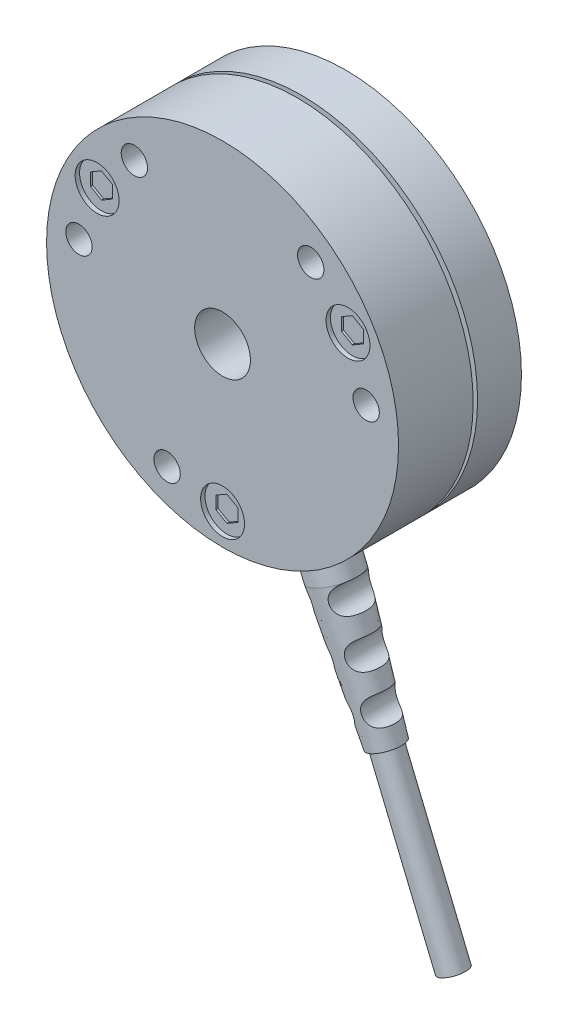
from build123d import *

# Parameters (mm, degrees)
SKETCH1_R           = 20.05
BOSS_EXTRUDE1_DEPTH = 5
SKETCH2_R           = 18.5
BOSS_EXTRUDE2_DEPTH = 0.5
SKETCH3_R           = 20.05
BOSS_EXTRUDE3_DEPTH = 8.5
SKETCH4_R           = 2.65
BOSS_EXTRUDE4_DEPTH = 37.35
CHAMFER1_SIZE       = 15
CHAMFER1_SIZE2      = 0.786116689
SKETCH5_R           = 1.5
BOSS_EXTRUDE5_DEPTH = 20
SKETCH6_R           = 1.5
CUT_EXTRUDE1_DEPTH  = 15.0000001
SKETCH9_R           = 2.5
CUT_EXTRUDE2_DEPTH  = 0.5
CUT_EXTRUDE3_DEPTH  = 0.25
SKETCH11_R          = 3.175
CUT_EXTRUDE4_DEPTH  = 15
SKETCH12_R          = 1.5
CUT_EXTRUDE5_DEPTH  = 5
SKETCH13_R          = 1.5
CUT_EXTRUDE6_DEPTH  = 5
SKETCH14_R          = 1.5
CUT_EXTRUDE7_DEPTH  = 5
SKETCH15_R          = 1.5
CUT_EXTRUDE8_DEPTH  = 5
SKETCH16_R          = 3.5
CUT_EXTRUDE9_DEPTH  = 0.5
CUT_EXTRUDE10_DEPTH = 0.25


with BuildPart() as part:
    # Sketch1 → Boss-Extrude1 (new body)
    with BuildSketch(Plane.XY):
        Circle(SKETCH1_R)
    extrude(amount=BOSS_EXTRUDE1_DEPTH)

    # Sketch2 → Boss-Extrude2 (add)
    with BuildSketch(Plane.XY.offset(5)):
        Circle(SKETCH2_R)
    extrude(amount=BOSS_EXTRUDE2_DEPTH)

    # Sketch3 → Boss-Extrude3 (add)
    with BuildSketch(Plane.XY.offset(5.5)):
        Circle(SKETCH3_R)
    extrude(amount=BOSS_EXTRUDE3_DEPTH)

    # Sketch4 → Boss-Extrude4 (add)
    with BuildSketch(Plane(origin=(0, 0, 0), x_dir=(0.923879533, 0.382683432, 0), z_dir=(-0.382683432, 0.923879533, 0))):
        with Locations((0, -9.65)):
            Circle(SKETCH4_R)
    extrude(amount=-BOSS_EXTRUDE4_DEPTH)

    # Chamfer1
    chamfer1_edges = [part.edges().sort_by_distance(p)[0] for p in [
        (11.844945438, -35.521011635, 9.65),
    ]]
    chamfer1_side = [part.faces().sort_by_distance(p)[0] for p in [
        (8.500185155, -27.446045997, 9.65),
    ]]
    chamfer(chamfer1_edges, length=CHAMFER1_SIZE, length2=CHAMFER1_SIZE2, reference=chamfer1_side[0])

    # Sketch5 → Boss-Extrude5 (add)
    with BuildSketch(Plane(origin=(14.293226199, -34.506900539, 0), x_dir=(-0.923879533, -0.382683432, 0), z_dir=(0.382683432, -0.923879533, 0))):
        with Locations((0, -9.65)):
            Circle(SKETCH5_R)
    extrude(amount=BOSS_EXTRUDE5_DEPTH)

    # Sketch6 → Cut-Extrude1 (cut, through all)
    with BuildSketch(Plane.XY):
        with Locations((11.501965763, -21.048558692)):
            Circle(SKETCH6_R)
        with Locations((13.173290552, -25.768234299)):
            Circle(SKETCH6_R)
        with Locations((14.844615341, -30.487909906)):
            Circle(SKETCH6_R)
        with Locations((11.061479667, -32.05493601)):
            Circle(SKETCH6_R)
        with Locations((8.905970132, -27.535816292)):
            Circle(SKETCH6_R)
        with Locations((6.750460597, -23.016696574)):
            Circle(SKETCH6_R)
    extrude(amount=CUT_EXTRUDE1_DEPTH, mode=Mode.SUBTRACT)

    # Sketch9 → Cut-Extrude2 (cut)
    with BuildSketch(Plane.XY.offset(14)):
        with Locations((0, -16.5)):
            Circle(SKETCH9_R)
        with Locations((-14.289419162, 8.25)):
            Circle(SKETCH9_R)
        with Locations((14.289419162, 8.25)):
            Circle(SKETCH9_R)
    extrude(amount=-CUT_EXTRUDE2_DEPTH, mode=Mode.SUBTRACT)

    # Sketch10 → Cut-Extrude3 (cut)
    with BuildSketch(Plane.XY.offset(13.5)):
        Polygon((-15.539419162, 8.971687836), (-15.539419162, 7.528312164), (-14.289419162, 6.806624327), (-13.039419162, 7.528312164), (-13.039419162, 8.971687836), (-14.289419162, 9.693375673), align=None)
        Polygon((0, -17.943375673), (1.25, -17.221687836), (1.25, -15.778312164), (0, -15.056624327), (-1.25, -15.778312164), (-1.25, -17.221687836), align=None)
        Polygon((15.539419162, 8.971687836), (14.289419162, 9.693375673), (13.039419162, 8.971687836), (13.039419162, 7.528312164), (14.289419162, 6.806624327), (15.539419162, 7.528312164), align=None)
    extrude(amount=-CUT_EXTRUDE3_DEPTH, mode=Mode.SUBTRACT)

    # Sketch11 → Cut-Extrude4 (cut, through all)
    with BuildSketch(Plane.XY.offset(14)):
        Circle(SKETCH11_R)
    extrude(amount=-CUT_EXTRUDE4_DEPTH, mode=Mode.SUBTRACT)

    # Sketch12 → Cut-Extrude5 (cut)
    with BuildSketch(Plane.XY.offset(14)):
        with Locations((-6.314276634, -15.244012286)):
            Circle(SKETCH12_R)
        with Locations((-10.044563579, 13.090330115)):
            Circle(SKETCH12_R)
        with Locations((16.358840213, 2.153682172)):
            Circle(SKETCH12_R)
    extrude(amount=-CUT_EXTRUDE5_DEPTH, mode=Mode.SUBTRACT)

    # Sketch13 → Cut-Extrude6 (cut)
    with BuildSketch(Plane.XY.offset(14)):
        with Locations((-16.358840213, 2.153682172)):
            Circle(SKETCH13_R)
        with Locations((10.044563579, 13.090330115)):
            Circle(SKETCH13_R)
    extrude(amount=-CUT_EXTRUDE6_DEPTH, mode=Mode.SUBTRACT)

    # Sketch14 → Cut-Extrude7 (cut)
    with BuildSketch(Plane(origin=(0, 0, 0), x_dir=(-1, 0, 0), z_dir=(0, 0, -1))):
        with Locations((0, -16.5)):
            Circle(SKETCH14_R)
        with Locations((-14.289419162, 8.25)):
            Circle(SKETCH14_R)
        with Locations((14.289419162, 8.25)):
            Circle(SKETCH14_R)
    extrude(amount=-CUT_EXTRUDE7_DEPTH, mode=Mode.SUBTRACT)

    # Sketch15 → Cut-Extrude8 (cut)
    with BuildSketch(Plane(origin=(0, 0, 0), x_dir=(-1, 0, 0), z_dir=(0, 0, -1))):
        with Locations((0, 17.5)):
            Circle(SKETCH15_R)
        with Locations((-15.155444566, -8.75)):
            Circle(SKETCH15_R)
    extrude(amount=-CUT_EXTRUDE8_DEPTH, mode=Mode.SUBTRACT)

    # Sketch16 → Cut-Extrude9 (cut)
    with BuildSketch(Plane(origin=(0, 0, 0), x_dir=(-1, 0, 0), z_dir=(0, 0, -1))):
        with Locations((0, -7.5)):
            Circle(SKETCH16_R)
        with Locations((-6.495190528, 3.75)):
            Circle(SKETCH16_R)
        with Locations((6.495190528, 3.75)):
            Circle(SKETCH16_R)
    extrude(amount=-CUT_EXTRUDE9_DEPTH, mode=Mode.SUBTRACT)

    # Sketch17 → Cut-Extrude10 (cut)
    with BuildSketch(Plane(origin=(0, 0, 0.5), x_dir=(-1, 0, 0), z_dir=(0, 0, -1))):
        Polygon((-7.745190528, 4.471687836), (-7.745190528, 3.028312164), (-6.495190528, 2.306624327), (-5.245190528, 3.028312164), (-5.245190528, 4.471687836), (-6.495190528, 5.193375673), align=None)
        Polygon((0, -8.943375673), (1.25, -8.221687836), (1.25, -6.778312164), (0, -6.056624327), (-1.25, -6.778312164), (-1.25, -8.221687836), align=None)
        Polygon((7.745190528, 4.471687836), (6.495190528, 5.193375673), (5.245190528, 4.471687836), (5.245190528, 3.028312164), (6.495190528, 2.306624327), (7.745190528, 3.028312164), align=None)
    extrude(amount=-CUT_EXTRUDE10_DEPTH, mode=Mode.SUBTRACT)


solid = part.part
